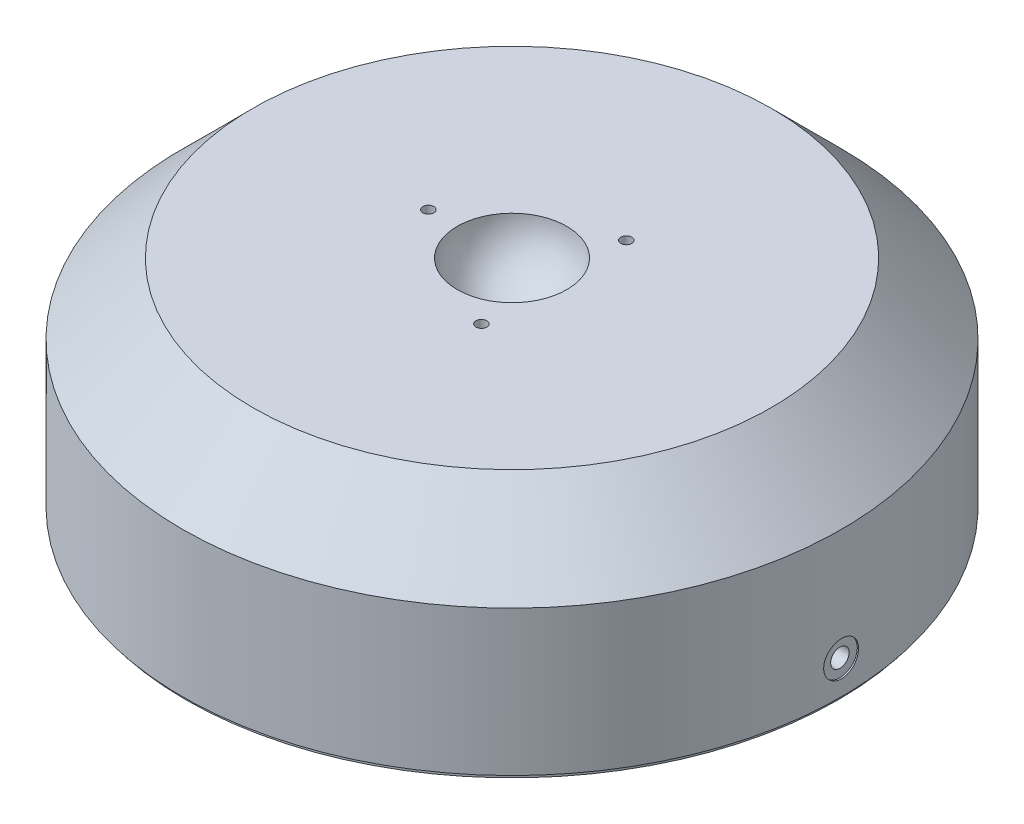
from build123d import *

# Parameters (mm, degrees)
SKETCH1_R                          = 76.2
MAIN_EXTRUDE_DEPTH                 = 50.5582
SKETCH4_R                          = 76.2
SKETCH4_R_2                        = 75.057
TURN_OUTSIDE_DEPTH                 = 37.846
SKETCH5_R                          = 74.295
EXTRUDE1_DEPTH                     = 0.9906
SKETCH7_R                          = 76.2
FACE_BOTTOM_DEPTH                  = 1.5367
SKETCH8_R                          = 76.2
SKETCH8_R_2                        = 75.057
TURN_REST_OF_OUTSIDE_DEPTH         = 12.1755
SKETCH3_R                          = 2.3876
PILOT_HOLE_FOR_BALL_DEPTH          = 12.446
SPHERICAL_BALL_ANGLE               = 180
CHAMFER1_SIZE                      = 16.002
F_5_16_0_3125_DIAMETER_HOLE1_D     = 7.9375
F_5_16_0_3125_DIAMETER_HOLE1_DEPTH = 0.508
RETAINER_HOLE_PATTERN_COUNT        = 3
M5X0_8_TAPPED_HOLE1_D              = 4.2
M5X0_8_TAPPED_HOLE1_DEPTH          = 66.675
M5X0_8_TAPPED_HOLE1_TIP            = 1.2618073


with BuildPart() as part:
    # Sketch1 → Main Extrude (new body)
    with BuildSketch(Plane(origin=(0, 0, 0), x_dir=(1, 0, 0), z_dir=(0, 1, 0))):
        with Locations(Location((0, 0, 0), (0, 0, 270))):  # turned: the seam where the file's is
            Circle(SKETCH1_R)
    extrude(amount=MAIN_EXTRUDE_DEPTH)

    # Sketch4 → Turn Outside (cut)
    with BuildSketch(Plane.XZ):
        with Locations(Location((0, 0, 0), (0, 0, 270))):  # turned: the seam where the file's is
            Circle(SKETCH4_R)
        with Locations(Location((0, 0, 0), (0, 0, 270))):  # turned: the seam where the file's is
            Circle(SKETCH4_R_2, mode=Mode.SUBTRACT)
    extrude(amount=-TURN_OUTSIDE_DEPTH, mode=Mode.SUBTRACT)

    # Sketch5 → Extrude1 (add)
    with BuildSketch(Plane.XZ):
        with Locations(Location((0, 0, 0), (0, 0, 90))):  # turned: the seam where the file's is
            Circle(SKETCH5_R)
    extrude(amount=EXTRUDE1_DEPTH)

    # Sketch7 → Face Bottom (cut)
    with BuildSketch(Plane(origin=(0, 50.5582, 0), x_dir=(-1, 0, 0), z_dir=(0, 1, 0))):
        with Locations(Location((0, 0, 0), (0, 0, 270))):  # turned: the seam where the file's is
            Circle(SKETCH7_R)
    extrude(amount=-FACE_BOTTOM_DEPTH, mode=Mode.SUBTRACT)

    # Sketch8 → Turn rest of outside (cut, through all)
    with BuildSketch(Plane.XZ.offset(-37.846)):
        Circle(SKETCH8_R)
        with Locations(Location((0, 0, 0), (0, 0, 270))):  # turned: the seam where the file's is
            Circle(SKETCH8_R_2, mode=Mode.SUBTRACT)
    extrude(amount=-TURN_REST_OF_OUTSIDE_DEPTH, mode=Mode.SUBTRACT)

    # Sketch3 → Pilot hole for ball (cut)
    with BuildSketch(Plane(origin=(0, 49.0215, 0), x_dir=(-1, 0, 0), z_dir=(0, 1, 0))):
        with Locations(Location((0, 0, 0), (0, 0, 90))):  # turned: the seam where the file's is
            Circle(SKETCH3_R)
    extrude(amount=-PILOT_HOLE_FOR_BALL_DEPTH, mode=Mode.SUBTRACT)

    # Sketch2 → Spherical Ball (revolve, cut)
    with BuildSketch(Plane(origin=(0, 49.5295, 0), x_dir=(-1, 0, 0), z_dir=(0, 1, 0))):
        with BuildLine():
            Line((12.499975, 0), (-12.499975, 0))
            ThreePointArc((-12.499975, 0), (0, -12.499975), (12.499975, 0))
        make_face()
    revolve(axis=Axis((-12.499975, 49.5295, 0), (-1, 0, 0)), revolution_arc=SPHERICAL_BALL_ANGLE, mode=Mode.SUBTRACT)

    # Chamfer1
    chamfer1_edges = [part.edges().sort_by_distance(p)[0] for p in [
        (0, 49.0215, 75.057),
    ]]
    chamfer(chamfer1_edges, length=CHAMFER1_SIZE)

    # 5_16 _0.3125_ Diameter Hole1
    with Locations(Plane(origin=(75.184, 0, 0), x_dir=(0, 0, -1), z_dir=(1, 0, 0))):
        with Locations((0, 7.5179)):
            Hole(F_5_16_0_3125_DIAMETER_HOLE1_D / 2, depth=F_5_16_0_3125_DIAMETER_HOLE1_DEPTH)

    # Sketch15 → M3x0.5 Retainer Hole (revolve, cut)
    with BuildSketch(Plane(origin=(-19.05, 49.0215, 0), x_dir=(0, 0, 1), z_dir=(1, 0, 0))):
        Polygon((0, 0), (0, 8.599675774), (1.25, 7.8486), (1.25, 0), align=None)
    m3x0_5_retainer_hole = revolve(axis=Axis((-19.05, 55.3715, 0), (0, -1, 0)), mode=Mode.SUBTRACT)

    # Retainer hole pattern: M3x0.5 Retainer Hole ×3 about axis
    retainer_hole_pattern_axis = Axis((0, 0, 0), (0, 1, 0))
    for i in range(1, RETAINER_HOLE_PATTERN_COUNT):
        add(m3x0_5_retainer_hole.rotate(retainer_hole_pattern_axis, i * 360 / RETAINER_HOLE_PATTERN_COUNT), mode=Mode.SUBTRACT)

    # M5x0.8 Tapped Hole1
    with Locations(Plane(origin=(74.676, 0, 0), x_dir=(0, 0, -1), z_dir=(1, 0, 0))):
        with Locations((0, 7.5179)):
            Hole(M5X0_8_TAPPED_HOLE1_D / 2, depth=M5X0_8_TAPPED_HOLE1_DEPTH)
            with Locations((0, 0, -(M5X0_8_TAPPED_HOLE1_DEPTH + M5X0_8_TAPPED_HOLE1_TIP / 2))):  # 118° drill point
                Cone(0, M5X0_8_TAPPED_HOLE1_D / 2, M5X0_8_TAPPED_HOLE1_TIP, mode=Mode.SUBTRACT)


solid = part.part
